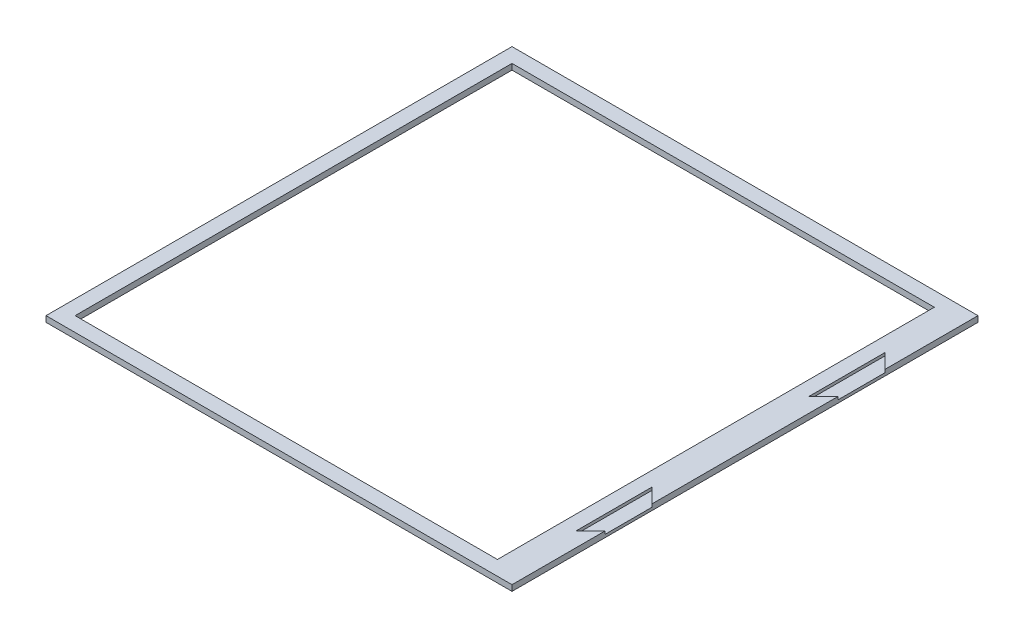
from build123d import *

# Parameters (mm, degrees)
SKETCH1_W           = 203.2
SKETCH1_H           = 203.2
SKETCH1_W_2         = 190.5
SKETCH1_H_2         = 190.5
BOSS_EXTRUDE1_DEPTH = 1.27
SKETCH2_W           = 6.35
SKETCH2_H           = 190.5
BOSS_EXTRUDE2_DEPTH = 1.27
CUT_EXTRUDE1_DEPTH  = 1.27


with BuildPart() as part:
    # Sketch1 → Boss-Extrude1 (new body, symmetric)
    with BuildSketch(Plane(origin=(0, 0, 0), x_dir=(1, 0, 0), z_dir=(0, 1, 0))):
        Rectangle(SKETCH1_W, SKETCH1_H)
        Rectangle(SKETCH1_W_2, SKETCH1_H_2, mode=Mode.SUBTRACT)
    extrude(amount=BOSS_EXTRUDE1_DEPTH, both=True)

    # Sketch2 → Boss-Extrude2 (add, symmetric)
    with BuildSketch(Plane(origin=(0, 0, 0), x_dir=(1, 0, 0), z_dir=(0, 1, 0))):
        with Locations((92.075, 0)):
            Rectangle(SKETCH2_W, SKETCH2_H)
    extrude(amount=BOSS_EXTRUDE2_DEPTH, both=True)

    # Sketch3 → Cut-Extrude1 (cut)
    with BuildSketch(Plane(origin=(0, 1.27, 0), x_dir=(1, 0, 0), z_dir=(0, 1, 0))):
        Polygon((101.6, 40.64), (95.25, 34.29), (95.25, 67.31), (101.6, 60.96), align=None)
        Polygon((101.6, -60.96), (101.6, -40.64), (95.25, -34.29), (95.25, -67.31), align=None)
    extrude(amount=-CUT_EXTRUDE1_DEPTH, mode=Mode.SUBTRACT)


solid = part.part
